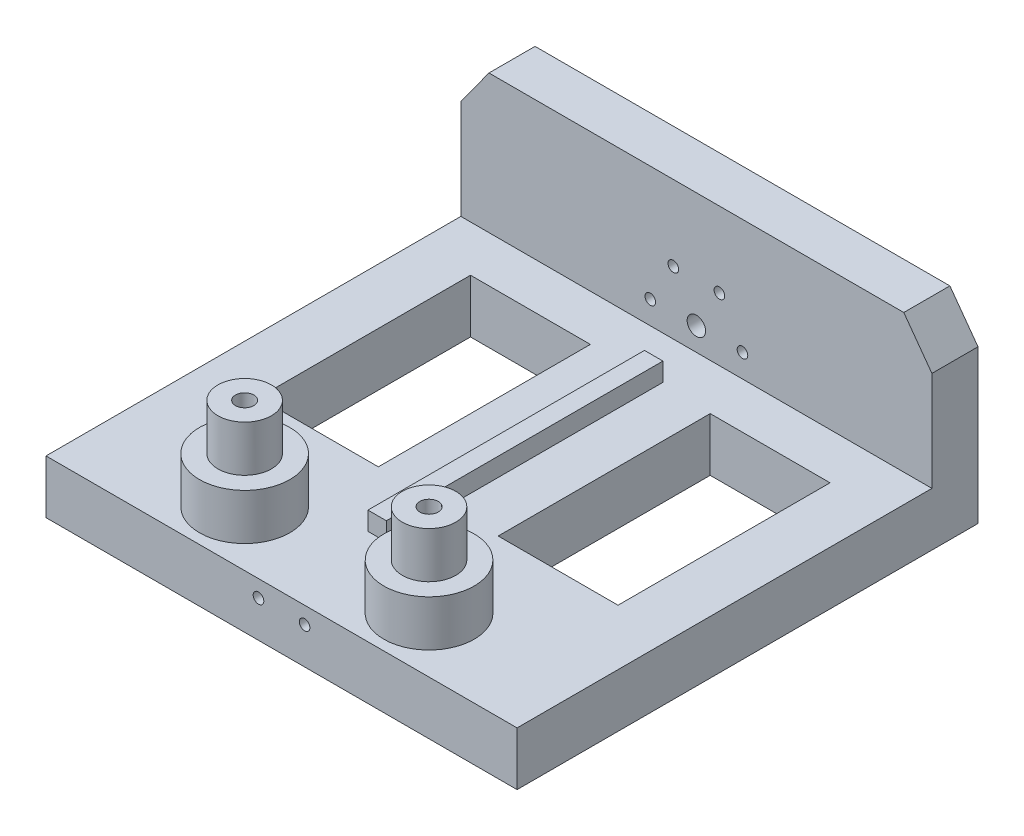
from build123d import *

# Parameters (mm, degrees)
SKETCH1_R               = 1
SKETCH1_R_2             = 0.575
BOSS_EXTRUDE1_DEPTH     = 5
SKETCH2_R               = 0.575
BOSS_EXTRUDE2_DEPTH     = 45
SKETCH4_W               = 2
SKETCH4_H               = 30
BOSS_EXTRUDE3_DEPTH     = 2
SKETCH5_W               = 13
SKETCH5_H               = 23
CUT_EXTRUDE1_DEPTH      = 16
SKETCH6_R               = 2.9
BOSS_EXTRUDE4_DEPTH     = 10
SKETCH7_R               = 1
CUT_EXTRUDE2_DEPTH      = 60.605474742
CUT_EXTRUDE2_DEPTH_BACK = 60.605474742
SKETCH11_R              = 4.9
SKETCH11_R_2            = 2.9
BOSS_EXTRUDE5_DEPTH     = 5
CUT_EXTRUDE4_DEPTH      = 73.577548022
CUT_EXTRUDE4_DEPTH_BACK = 73.577548022


with BuildPart() as part:
    # Sketch1 → Boss-Extrude1 (new body)
    with BuildSketch(Plane.XY):
        Polygon((-22.5, 12.5), (22.5, 12.5), (25.550198027, 8.301762582), (25.550198027, -8.301762582), (22.5, -12.5), (-22.5, -12.5), (-25.550198027, -8.301762582), (-25.550198027, 8.301762582), align=None)
        Circle(SKETCH1_R, mode=Mode.SUBTRACT)
        with Locations((-5, 0)):
            Circle(SKETCH1_R_2, mode=Mode.SUBTRACT)
        with Locations((-2.5, 4.330127019)):
            Circle(SKETCH1_R_2, mode=Mode.SUBTRACT)
        with Locations((2.5, 4.330127019)):
            Circle(SKETCH1_R_2, mode=Mode.SUBTRACT)
        with Locations((5, 0)):
            Circle(SKETCH1_R_2, mode=Mode.SUBTRACT)
        with Locations((2.5, -4.330127019)):
            Circle(SKETCH1_R_2, mode=Mode.SUBTRACT)
        with Locations((-2.5, -4.330127019)):
            Circle(SKETCH1_R_2, mode=Mode.SUBTRACT)
    extrude(amount=BOSS_EXTRUDE1_DEPTH)

    # Sketch2 → Boss-Extrude2 (add)
    with BuildSketch(Plane.XY.offset(5)):
        Polygon((25.550198027, -2.5), (-25.550198027, -2.5), (-25.550198027, -8.301762582), (-22.5, -12.5), (22.5, -12.5), (25.550198027, -8.301762582), align=None)
        with Locations((-2.5, -4.330127019)):
            Circle(SKETCH2_R, mode=Mode.SUBTRACT)
        with Locations((2.5, -4.330127019)):
            Circle(SKETCH2_R, mode=Mode.SUBTRACT)
    extrude(amount=BOSS_EXTRUDE2_DEPTH)

    # Sketch4 → Boss-Extrude3 (add)
    with BuildSketch(Plane(origin=(0, -2.5, 0), x_dir=(1, 0, 0), z_dir=(0, 1, 0))):
        with Locations((0, -24.628925384)):
            Rectangle(SKETCH4_W, SKETCH4_H)
    extrude(amount=BOSS_EXTRUDE3_DEPTH)

    # Sketch5 → Cut-Extrude1 (cut)
    with BuildSketch(Plane(origin=(0, -2.5, 0), x_dir=(1, 0, 0), z_dir=(0, 1, 0))):
        with Locations((13, -21.5)):
            Rectangle(SKETCH5_W, SKETCH5_H)
        with Locations((-13, -21.5)):
            Rectangle(SKETCH5_W, SKETCH5_H)
    extrude(amount=-CUT_EXTRUDE1_DEPTH, mode=Mode.SUBTRACT)

    # Sketch6 → Boss-Extrude4 (add)
    with BuildSketch(Plane(origin=(0, -2.5, 0), x_dir=(1, 0, 0), z_dir=(0, 1, 0))):
        with Locations(Location((10, -44, 0), (0, 0, 270))):
            Circle(SKETCH6_R)
        with Locations(Location((-10, -44, 0), (0, 0, 90))):
            Circle(SKETCH6_R)
    extrude(amount=BOSS_EXTRUDE4_DEPTH)

    # Sketch7 → Cut-Extrude2 (cut, two sides)
    with BuildSketch(Plane(origin=(0, 7.5, 0), x_dir=(1, 0, 0), z_dir=(0, 1, 0))) as cut_extrude2_sk:
        with Locations(Location((10, -44, 0), (0, 0, 270))):
            Circle(SKETCH7_R)
        with Locations(Location((-10, -44, 0), (0, 0, 270))):
            Circle(SKETCH7_R)
    extrude(amount=CUT_EXTRUDE2_DEPTH, mode=Mode.SUBTRACT)
    extrude(cut_extrude2_sk.sketch, amount=-CUT_EXTRUDE2_DEPTH_BACK, mode=Mode.SUBTRACT)

    # Sketch11 → Boss-Extrude5 (add)
    with BuildSketch(Plane(origin=(0, -2.5, 0), x_dir=(1, 0, 0), z_dir=(0, 1, 0))):
        with Locations(Location((-10, -44, 0), (0, 0, 270))):
            Circle(SKETCH11_R)
        with Locations(Location((-10, -44, 0), (0, 0, 90))):
            Circle(SKETCH11_R_2, mode=Mode.SUBTRACT)
        with Locations(Location((10, -44, 0), (0, 0, 270))):
            Circle(SKETCH11_R)
        with Locations(Location((10, -44, 0), (0, 0, 270))):
            Circle(SKETCH11_R_2, mode=Mode.SUBTRACT)
    extrude(amount=BOSS_EXTRUDE5_DEPTH)

    # Sketch13 → Cut-Extrude4 (cut, two sides)
    with BuildSketch(Plane.ZY.offset(25.550198027)) as cut_extrude4_sk:
        Polygon((0, -8.301762582), (-5.234948532, -12.24807669), (12.300258877, -20.537447465), (51.143400136, -17.827460865), (57.147880249, -8.301762582), (50, -8.301762582), align=None)
    extrude(amount=CUT_EXTRUDE4_DEPTH, mode=Mode.SUBTRACT)
    extrude(cut_extrude4_sk.sketch, amount=-CUT_EXTRUDE4_DEPTH_BACK, mode=Mode.SUBTRACT)


solid = part.part
